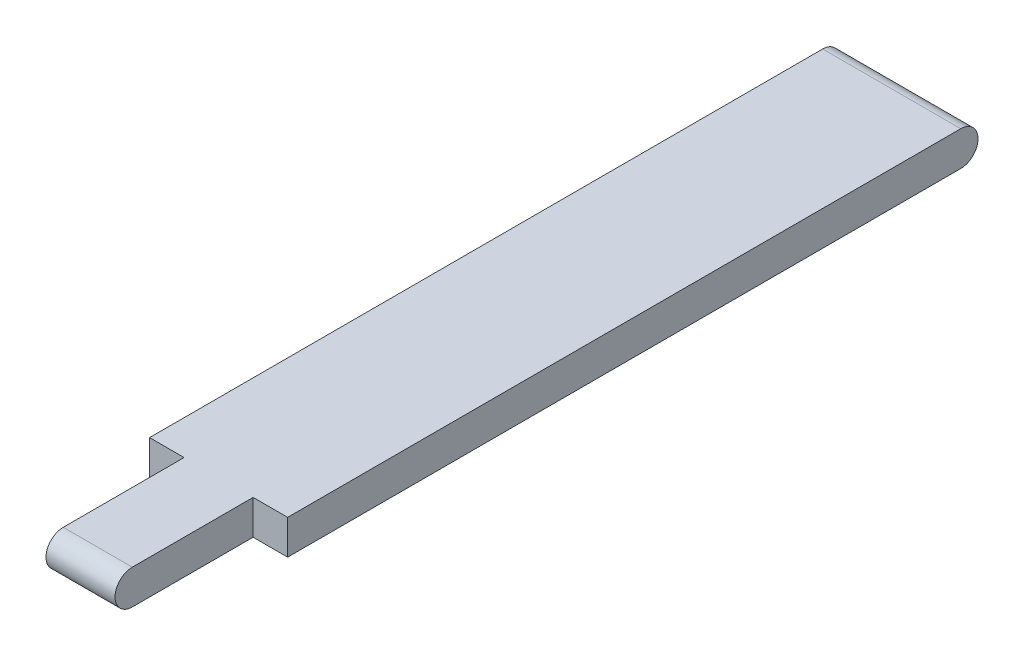
from build123d import *

# Parameters (mm, degrees)
EXTRUDE_1_DEPTH     = 4
SKETCH_5_W          = 2
SKETCH_5_H          = 8
CUT_EXTRUDE_2_DEPTH = 10


with BuildPart() as part:
    # 草图1 → 凸台-拉伸1 (new body, symmetric)
    with BuildSketch(Plane(origin=(0, 0, 0), x_dir=(0, 0, -1), z_dir=(1, 0, 0))):
        with BuildLine():
            Line((-23, 1), (23, 1))
            ThreePointArc((23, 1), (24, 0), (23, -1))
            Line((23, -1), (-23, -1))
            ThreePointArc((-23, -1), (-24, 0), (-23, 1))
        make_face()
    extrude(amount=EXTRUDE_1_DEPTH, both=True)

    # 草图5 → 切除-拉伸2 (cut)
    with BuildSketch(Plane(origin=(0, 1, 0), x_dir=(1, 0, 0), z_dir=(0, 1, 0))):
        with Locations((-3, -20)):
            Rectangle(SKETCH_5_W, SKETCH_5_H)
        with Locations((3, -20)):
            Rectangle(SKETCH_5_W, SKETCH_5_H)
    extrude(amount=-CUT_EXTRUDE_2_DEPTH, mode=Mode.SUBTRACT)


solid = part.part
